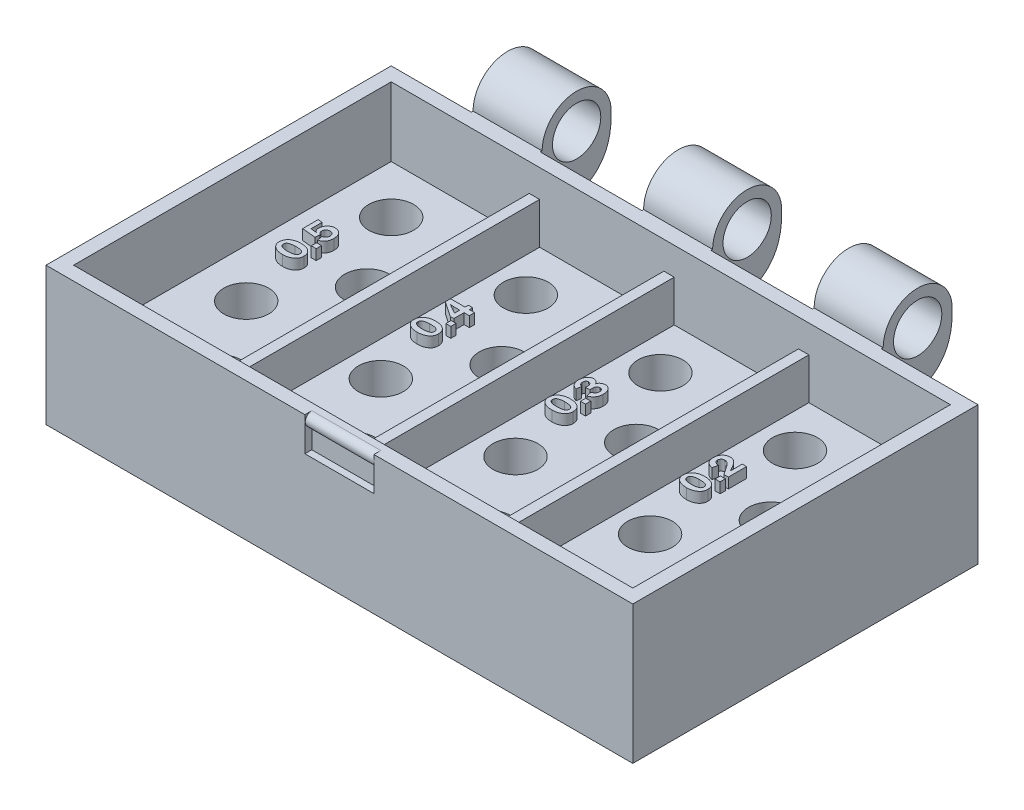
from build123d import *

# Parameters (mm, degrees)
ESQUISSE1_W                  = 85
ESQUISSE1_H                  = 50
BOSS_EXTRU_1_DEPTH           = 20
COQUE1_T                     = -2
COQUE1_THICKNESS_2_FACE_W    = 46
COQUE1_THICKNESS_2_FACE_H    = 81
COQUE1_THICKNESS_2_DEPTH     = 8
ESQUISSE2_R                  = 3.25
ENL_V_MAT_EXTRU_1_DEPTH      = 6
R_P_TITION_LIN_AIRE1_COUNT   = 4
R_P_TITION_LIN_AIRE1_PITCH   = 19.5
ESQUISSE3_W                  = 1.5
ESQUISSE3_H                  = 46
BOSS_EXTRU_2_DEPTH           = 6
R_P_TITION_LIN_AIRE2_COUNT   = 3
R_P_TITION_LIN_AIRE2_PITCH   = 19.5
ESQUISSE6_W                  = 0.719178082
ESQUISSE6_H                  = 0.767123288
BOSS_EXTRU_4_DEPTH           = 1.5
ESQUISSE7_R                  = 5
BOSS_EXTRU_5_DEPTH           = 10
ESQUISSE8_R                  = 3.5
ENL_V_MAT_EXTRU_2_DEPTH      = 10
R_P_TITION_LIN_AIRE4_COUNT   = 3
R_P_TITION_LIN_AIRE4_PITCH   = 24.7
ENL_V_MAT_EXTRU_3_DEPTH      = 5
ENL_V_MAT_EXTRU_3_DEPTH_BACK = 5


with BuildPart() as part:
    # Esquisse1 → Boss.-Extru.1 (new body)
    with BuildSketch(Plane(origin=(0, 0, 0), x_dir=(1, 0, 0), z_dir=(0, 1, 0))):
        Rectangle(ESQUISSE1_W, ESQUISSE1_H)
    extrude(amount=BOSS_EXTRU_1_DEPTH)

    # Coque1
    coque1_openings = [part.faces().sort_by_distance(p)[0] for p in [
        (0, 20, 0),
    ]]
    offset(amount=COQUE1_T, openings=coque1_openings, kind=Kind.INTERSECTION)

    # Coque1 thickness 2 face (on inner face of the shell) → Coque1 thickness 2 (add)
    with BuildSketch(Plane(origin=(0, 2, 0), x_dir=(0, 0, -1), z_dir=(0, -1, 0))):
        Rectangle(COQUE1_THICKNESS_2_FACE_W, COQUE1_THICKNESS_2_FACE_H)
    extrude(amount=-COQUE1_THICKNESS_2_DEPTH)

    # Esquisse2 → Enlèv. mat.-Extru.1 (cut)
    with BuildSketch(Plane(origin=(0, 10, 0), x_dir=(1, 0, 0), z_dir=(0, 1, 0))):
        with Locations(Location((-26.5, 5.5, 0), (0, 0, 270))):
            Circle(ESQUISSE2_R)
        with Locations(Location((-26.5, -16, 0), (0, 0, 270))):
            Circle(ESQUISSE2_R)
        with Locations(Location((-33.5, -5, 0), (0, 0, 270))):
            Circle(ESQUISSE2_R)
        with Locations(Location((-33.5, 16, 0), (0, 0, 270))):
            Circle(ESQUISSE2_R)
    enl_v_mat_extru_1 = extrude(amount=-ENL_V_MAT_EXTRU_1_DEPTH, mode=Mode.SUBTRACT)

    # Répétition linéaire1: Enlèv. mat.-Extru.1 ×4
    with Locations(*[(i * R_P_TITION_LIN_AIRE1_PITCH, 0, 0) for i in range(1, R_P_TITION_LIN_AIRE1_COUNT)]):
        add(enl_v_mat_extru_1, mode=Mode.SUBTRACT)

    # Esquisse3 → Boss.-Extru.2 (add)
    with BuildSketch(Plane(origin=(0, 10, 0), x_dir=(1, 0, 0), z_dir=(0, 1, 0))):
        with Locations((-19.75, 0)):
            Rectangle(ESQUISSE3_W, ESQUISSE3_H)
    boss_extru_2 = extrude(amount=BOSS_EXTRU_2_DEPTH)

    # Répétition linéaire2: Boss.-Extru.2 ×3
    with Locations(*[(i * R_P_TITION_LIN_AIRE2_PITCH, 0, 0) for i in range(1, R_P_TITION_LIN_AIRE2_COUNT)]):
        add(boss_extru_2)

    # Esquisse6 → Boss.-Extru.4 (add)
    with BuildSketch(Plane(origin=(0, 10, 0), x_dir=(1, 0, 0), z_dir=(0, 1, 0))):
        with BuildLine():
            Line((-37, 6.679152397), (-37, 8.928082192))
            Line((-37, 8.928082192), (-36.376712329, 8.867401541))
            Line((-36.376712329, 8.867401541), (-36.376712329, 7.267979452))
            Line((-36.376712329, 7.267979452), (-35.505458048, 7.174336473))
            add(Edge.make_bspline(
                [(-35.505458048, 7.174336473), (-35.536788442, 7.190319678), (-35.597993464, 7.221543429), (-35.677964947, 7.28451081), (-35.747036538, 7.356149542), (-35.801696297, 7.439908994), (-35.844762934, 7.533057182), (-35.875351885, 7.636477261), (-35.894328605, 7.749979407), (-35.89626044, 7.829259295), (-35.897260274, 7.870291096)],
                knots=[0, 0, 0, 0, 0.992987196, 1.939835233, 2.864410788, 3.797156695, 4.754959799, 5.758547693, 6.839922347, 8, 8, 8, 8], degree=3))
            add(Edge.make_bspline(
                [(-35.897260274, 7.870291096), (-35.896442983, 7.914306971), (-35.894838897, 8.000696413), (-35.87657293, 8.127238371), (-35.849403012, 8.248304314), (-35.810314185, 8.363626685), (-35.759486092, 8.472740789), (-35.698950694, 8.577023251), (-35.625584511, 8.674370878), (-35.542881375, 8.765226882), (-35.452799974, 8.847557534), (-35.358768745, 8.920719258), (-35.260520581, 8.981547302), (-35.159760441, 9.032429891), (-35.055005573, 9.071679877), (-34.9466723, 9.098956569), (-34.835101776, 9.117372213), (-34.759385456, 9.119026587), (-34.721104452, 9.119863014)],
                knots=[0, 0, 0, 0, 1.107094003, 2.17288043, 3.211198401, 4.226878603, 5.230841999, 6.236594203, 7.256079046, 8.292778735, 9.324838043, 10.324285764, 11.287009906, 12.228657515, 13.161453271, 14.095941559, 15.037337412, 16, 16, 16, 16], degree=3))
            add(Edge.make_bspline(
                [(-34.721104452, 9.119863014), (-34.681341285, 9.118656571), (-34.60244036, 9.116262662), (-34.486099148, 9.098798041), (-34.373354368, 9.069350181), (-34.264532111, 9.02781339), (-34.158913087, 8.975212582), (-34.057617206, 8.91018366), (-33.959725849, 8.834082224), (-33.866576909, 8.746921976), (-33.780423638, 8.64942117), (-33.70525665, 8.541509548), (-33.640910856, 8.424703728), (-33.589606205, 8.298016432), (-33.548846819, 8.162642969), (-33.520978793, 8.018047737), (-33.503323629, 7.864485401), (-33.501128411, 7.758969042), (-33.5, 7.704730308)],
                knots=[0, 0, 0, 0, 0.912745112, 1.811134253, 2.694171492, 3.583292575, 4.480693289, 5.398394714, 6.342229601, 7.323843977, 8.323245794, 9.323683117, 10.337193912, 11.378459732, 12.455889876, 13.578032625, 14.755032447, 16, 16, 16, 16], degree=3))
            add(Edge.make_bspline(
                [(-33.5, 7.704730308), (-33.500775705, 7.663506791), (-33.502310817, 7.581925849), (-33.512806257, 7.461534651), (-33.530682073, 7.344871315), (-33.556424318, 7.232356809), (-33.588251851, 7.123498417), (-33.628405645, 7.01869055), (-33.675530385, 6.917836095), (-33.729174886, 6.820848616), (-33.7910182, 6.729624251), (-33.86352779, 6.646698683), (-33.945718391, 6.572390008), (-34.037154443, 6.505696778), (-34.138729686, 6.448362019), (-34.249582539, 6.398791865), (-34.369912236, 6.357263902), (-34.454455206, 6.337302819), (-34.497859589, 6.327054795)],
                knots=[0, 0, 0, 0, 1.06162628, 2.100948116, 3.109654542, 4.0987975, 5.071453937, 6.028161296, 6.986251055, 7.936342776, 8.879991641, 9.81893904, 10.765913088, 11.728116642, 12.727616964, 13.763909979, 14.851990799, 16, 16, 16, 16], degree=3))
            Line((-34.497859589, 6.327054795), (-34.602739726, 7.073202055))
            add(Edge.make_bspline(
                [(-34.602739726, 7.073202055), (-34.561123565, 7.088188019), (-34.481426963, 7.116886735), (-34.372971034, 7.174115585), (-34.281365429, 7.241082059), (-34.205543982, 7.316696614), (-34.146710976, 7.401962522), (-34.105135513, 7.496489145), (-34.079667848, 7.600020097), (-34.076812193, 7.672118237), (-34.075342466, 7.709225171)],
                knots=[0, 0, 0, 0, 1.190002395, 2.278901834, 3.288895901, 4.235075517, 5.14897565, 6.061093045, 7.002097791, 8, 8, 8, 8], degree=3))
            add(Edge.make_bspline(
                [(-34.075342466, 7.709225171), (-34.075943352, 7.734468311), (-34.077106855, 7.783346851), (-34.085369095, 7.854590848), (-34.09948881, 7.921353861), (-34.119423854, 7.983838343), (-34.146342116, 8.041230788), (-34.177271495, 8.094889384), (-34.215641674, 8.142983698), (-34.257935919, 8.187327219), (-34.305254456, 8.225737139), (-34.354873364, 8.260051288), (-34.407680192, 8.288176843), (-34.462215944, 8.312642176), (-34.519856358, 8.330632899), (-34.57987339, 8.342932825), (-34.642177138, 8.351917259), (-34.684612922, 8.352463077), (-34.706121575, 8.352739726)],
                knots=[0, 0, 0, 0, 1.193015732, 2.310048108, 3.384166337, 4.41432699, 5.401889314, 6.375529608, 7.334101736, 8.30236177, 9.266512726, 10.209332856, 11.149415557, 12.090164852, 13.030840104, 13.996146252, 14.984343142, 16, 16, 16, 16], degree=3))
            add(Edge.make_bspline(
                [(-34.706121575, 8.352739726), (-34.727379528, 8.35245716), (-34.769315976, 8.351899729), (-34.830650242, 8.343037952), (-34.889615369, 8.330491399), (-34.946107721, 8.312791809), (-34.99936841, 8.288187968), (-35.05072598, 8.259777174), (-35.099553312, 8.226057266), (-35.144810445, 8.187006186), (-35.18705162, 8.144879068), (-35.222830608, 8.098274643), (-35.253215739, 8.048699637), (-35.278849878, 7.996461801), (-35.298408636, 7.940627445), (-35.311724309, 7.881535244), (-35.320086542, 7.819587201), (-35.321301739, 7.777174202), (-35.321917808, 7.755672089)],
                knots=[0, 0, 0, 0, 1.061408398, 2.093884465, 3.090127335, 4.072834524, 5.044705628, 6.016817066, 7.003399267, 8.003698264, 9.000878628, 9.979377201, 10.931825108, 11.902974853, 12.881791689, 13.880766456, 14.925612437, 16, 16, 16, 16], degree=3))
            add(Edge.make_bspline(
                [(-35.321917808, 7.755672089), (-35.320810887, 7.725861776), (-35.318631829, 7.667177945), (-35.299997688, 7.58157188), (-35.269698215, 7.500342565), (-35.227106063, 7.423276523), (-35.172714585, 7.350186296), (-35.105989527, 7.281792642), (-35.027414468, 7.217668397), (-34.968737809, 7.180234457), (-34.938356164, 7.160851884)],
                knots=[0, 0, 0, 0, 0.962510054, 1.894773007, 2.816638911, 3.755688375, 4.730568976, 5.752162559, 6.836113034, 8, 8, 8, 8], degree=3))
            Line((-34.938356164, 7.160851884), (-35.041738014, 6.482876712))
            Line((-35.041738014, 6.482876712), (-37, 6.679152397))
        make_face()
        with Locations((-33.859589041, 5.523972603)):
            Rectangle(ESQUISSE6_W, ESQUISSE6_H)
        with BuildLine():
            add(Edge.make_bspline(
                [(-33.452054795, 3.308754281), (-33.453277057, 3.256709262), (-33.45566497, 3.155029823), (-33.480594161, 3.007557096), (-33.519189341, 2.869026264), (-33.574313111, 2.739791372), (-33.64520614, 2.620015611), (-33.731590094, 2.509260557), (-33.834206122, 2.408761505), (-33.951513136, 2.318544256), (-34.08013711, 2.238363245), (-34.217700769, 2.167290326), (-34.36422218, 2.108682552), (-34.51832965, 2.059524118), (-34.680793765, 2.022419993), (-34.85124655, 1.995714689), (-35.029904844, 1.978674456), (-35.151822794, 1.976921819), (-35.214041096, 1.976027397)],
                knots=[0, 0, 0, 0, 1.005007233, 1.963464982, 2.881621689, 3.778955867, 4.670391392, 5.564370843, 6.485806895, 7.4386222, 8.418802495, 9.411696762, 10.427102608, 11.465014262, 12.53503646, 13.644273268, 14.797803629, 16, 16, 16, 16], degree=3))
            add(Edge.make_bspline(
                [(-35.214041096, 1.976027397), (-35.280995538, 1.977269139), (-35.411864816, 1.979696249), (-35.603140375, 1.995951582), (-35.784381005, 2.02435189), (-35.955554331, 2.064181654), (-36.117520898, 2.113860798), (-36.269308898, 2.176378945), (-36.411445715, 2.249686971), (-36.542479415, 2.334154287), (-36.660695195, 2.428013347), (-36.7644758, 2.530352621), (-36.852211705, 2.641223996), (-36.923823732, 2.760369049), (-36.979840793, 2.887445888), (-37.019604463, 3.02234395), (-37.043095824, 3.165348052), (-37.046304785, 3.263218028), (-37.047945205, 3.313249144)],
                knots=[0, 0, 0, 0, 1.263317377, 2.469282517, 3.618848679, 4.721775781, 5.782855962, 6.811846994, 7.814967656, 8.796487561, 9.748685278, 10.658252565, 11.540562543, 12.409229823, 13.274196187, 14.153797078, 15.05622136, 16, 16, 16, 16], degree=3))
            add(Edge.make_bspline(
                [(-37.047945205, 3.313249144), (-37.047330518, 3.351740432), (-37.046125929, 3.427170937), (-37.033578612, 3.53781999), (-37.01432416, 3.643784024), (-36.987373468, 3.745026418), (-36.95312288, 3.841539305), (-36.909861959, 3.932515699), (-36.859717961, 4.019321297), (-36.801016775, 4.100470741), (-36.73657551, 4.177279934), (-36.665901483, 4.248085391), (-36.590797048, 4.314779463), (-36.509686499, 4.374973794), (-36.42425344, 4.430988897), (-36.332702113, 4.480278104), (-36.236608814, 4.525375539), (-36.10271786, 4.576001235), (-35.935449234, 4.627869147), (-35.738213682, 4.673820438), (-35.548316208, 4.703587071), (-35.423902733, 4.707159033), (-35.363120719, 4.70890411)],
                knots=[0, 0, 0, 0, 0.94187537, 1.845771813, 2.72221507, 3.57628802, 4.407725887, 5.22534137, 6.038925102, 6.858252631, 7.673808914, 8.490761443, 9.305033817, 10.130268942, 10.961077375, 11.803609458, 12.673290332, 13.557628104, 15.305455095, 16.95581214, 18.512766662, 20, 20, 20, 20], degree=3))
            add(Edge.make_bspline(
                [(-35.363120719, 4.70890411), (-35.314423312, 4.708392049), (-35.218989156, 4.707388544), (-35.079002427, 4.701907709), (-34.945400976, 4.690151928), (-34.818100669, 4.675762024), (-34.697483069, 4.655936827), (-34.583208303, 4.633433524), (-34.475928115, 4.604427248), (-34.374264246, 4.572405785), (-34.27750571, 4.535578353), (-34.185257655, 4.493005752), (-34.097437099, 4.443920993), (-34.013344904, 4.389914406), (-33.932798135, 4.330618108), (-33.856509703, 4.265459092), (-33.784214976, 4.19458846), (-33.716248507, 4.118579389), (-33.653508039, 4.037144552), (-33.599630312, 3.949104462), (-33.553819951, 3.855796062), (-33.515852481, 3.757151662), (-33.488077157, 3.652514238), (-33.466620819, 3.542975416), (-33.454922697, 3.427621078), (-33.453025376, 3.348982247), (-33.452054795, 3.308754281)],
                knots=[0, 0, 0, 0, 1.308115475, 2.563563526, 3.761728665, 4.90986614, 6.003763084, 7.044289273, 8.036748608, 8.987084304, 9.906402131, 10.81570635, 11.713458321, 12.606537478, 13.498658964, 14.397888098, 15.299091339, 16.215958955, 17.134909667, 18.056378292, 18.983299153, 19.923807997, 20.890361836, 21.887502022, 22.919344344, 24, 24, 24, 24], degree=3))
        make_face()
        with BuildLine():
            add(Edge.make_bspline(
                [(-34.02739726, 3.3125), (-34.029010421, 3.349625522), (-34.032130991, 3.421442768), (-34.059407377, 3.52371806), (-34.106085564, 3.61435351), (-34.171611183, 3.692759616), (-34.253538604, 3.759876227), (-34.352333048, 3.814540382), (-34.466166276, 3.858770753), (-34.572532587, 3.884214759), (-34.666223411, 3.90050561), (-34.745119076, 3.912038432), (-34.830938505, 3.920244724), (-34.92375181, 3.929107055), (-35.023453631, 3.934842652), (-35.130375672, 3.93809328), (-35.243984805, 3.941662627), (-35.32216425, 3.94174068), (-35.362371575, 3.941780822)],
                knots=[0, 0, 0, 0, 1.073429503, 2.076489368, 3.036773514, 4.002186882, 5.013884472, 6.085413537, 7.257387958, 8.539074557, 9.243873084, 10.010643218, 10.846512546, 11.739250192, 12.709684899, 13.736864371, 14.836079867, 16, 16, 16, 16], degree=3))
            add(Edge.make_bspline(
                [(-35.362371575, 3.941780822), (-35.428377608, 3.940242865), (-35.559110903, 3.937196747), (-35.751825589, 3.911546211), (-35.939040446, 3.871328424), (-36.088653369, 3.823939129), (-36.201119968, 3.777985747), (-36.273102289, 3.733334065), (-36.335765644, 3.683732243), (-36.385572045, 3.624678562), (-36.42564669, 3.55984727), (-36.451926447, 3.487057223), (-36.470412049, 3.408314256), (-36.471855718, 3.353071477), (-36.47260274, 3.324486301)],
                knots=[0, 0, 0, 0, 1.67541373, 3.318368768, 4.927723713, 6.531949127, 7.298762037, 8.004526205, 8.675958752, 9.319007099, 9.956245832, 10.60041861, 11.275791663, 12, 12, 12, 12], degree=3))
            add(Edge.make_bspline(
                [(-36.47260274, 3.324486301), (-36.471846413, 3.300934116), (-36.470367193, 3.254870818), (-36.455598577, 3.188137691), (-36.431771013, 3.125946128), (-36.396970373, 3.069096713), (-36.354006064, 3.016039183), (-36.301070076, 2.968056256), (-36.238351708, 2.925047275), (-36.166585412, 2.886247267), (-36.084684857, 2.852932615), (-35.994226816, 2.822831056), (-35.893922864, 2.798445487), (-35.784288961, 2.778646945), (-35.665142737, 2.76184017), (-35.536330576, 2.751238124), (-35.398158007, 2.744299459), (-35.302948916, 2.743542088), (-35.253745719, 2.743150685)],
                knots=[0, 0, 0, 0, 0.754198635, 1.475059561, 2.179865867, 2.880200645, 3.603015608, 4.362466504, 5.162094305, 6.036298937, 6.97312904, 7.993554671, 9.090789647, 10.279647763, 11.564904973, 12.947352574, 14.422419413, 16, 16, 16, 16], degree=3))
            add(Edge.make_bspline(
                [(-35.253745719, 2.743150685), (-35.207042861, 2.743623633), (-35.116344646, 2.74454211), (-34.984149209, 2.750440177), (-34.859903873, 2.760648989), (-34.743491144, 2.775838626), (-34.634610699, 2.794117522), (-34.533626496, 2.81738276), (-34.440143924, 2.844119336), (-34.354855482, 2.875309781), (-34.278068885, 2.910683248), (-34.211065958, 2.952088357), (-34.154583233, 2.999329187), (-34.107941246, 3.051742434), (-34.07130604, 3.109256428), (-34.045622708, 3.172429703), (-34.030382883, 3.24086055), (-34.028410021, 3.288198992), (-34.02739726, 3.3125)],
                knots=[0, 0, 0, 0, 1.497746712, 2.908664615, 4.242763532, 5.494342263, 6.672680141, 7.781939517, 8.815973326, 9.788908864, 10.691683796, 11.522736518, 12.307142226, 13.044689772, 13.764547329, 14.482844097, 15.221173818, 16, 16, 16, 16], degree=3))
        make_face(mode=Mode.SUBTRACT)
        Polygon((-14, 8.592465753), (-14, 7.825342466), (-14.767123288, 7.825342466), (-14.767123288, 6.339041096), (-15.282534247, 6.339041096), (-17.5, 7.847816781), (-17.5, 8.592465753), (-15.390410959, 8.592465753), (-15.390410959, 9.071917808), (-14.767123288, 9.071917808), (-14.767123288, 8.592465753), align=None)
        with BuildLine():
            Line((-16.805543664, 7.870291096), (-15.390410959, 7.067958048))
            Line((-15.390410959, 7.067958048), (-15.390410959, 7.825342466))
            Line((-15.390410959, 7.825342466), (-16.266909247, 7.825342466))
            add(Edge.make_bspline(
                [(-16.266909247, 7.825342466), (-16.314900716, 7.82578794), (-16.40503748, 7.826624623), (-16.494684651, 7.835960269), (-16.536601027, 7.840325342)],
                knots=[0, 0, 0, 0, 1.064858921, 2, 2, 2, 2], degree=3))
            Line((-16.536601027, 7.840325342), (-16.805543664, 7.870291096))
        make_face(mode=Mode.SUBTRACT)
        with Locations((-14.359589041, 5.523972603)):
            Rectangle(ESQUISSE6_W, ESQUISSE6_H)
        with BuildLine():
            add(Edge.make_bspline(
                [(-13.952054795, 3.308754281), (-13.953277057, 3.256709262), (-13.95566497, 3.155029823), (-13.980594161, 3.007557096), (-14.019189341, 2.869026264), (-14.074313111, 2.739791372), (-14.14520614, 2.620015611), (-14.231590094, 2.509260557), (-14.334206122, 2.408761505), (-14.451513136, 2.318544256), (-14.58013711, 2.238363245), (-14.717700769, 2.167290326), (-14.86422218, 2.108682552), (-15.01832965, 2.059524118), (-15.180793765, 2.022419993), (-15.35124655, 1.995714689), (-15.529904844, 1.978674456), (-15.651822794, 1.976921819), (-15.714041096, 1.976027397)],
                knots=[0, 0, 0, 0, 1.005007233, 1.963464982, 2.881621689, 3.778955867, 4.670391392, 5.564370843, 6.485806895, 7.4386222, 8.418802495, 9.411696762, 10.427102608, 11.465014262, 12.53503646, 13.644273268, 14.797803629, 16, 16, 16, 16], degree=3))
            add(Edge.make_bspline(
                [(-15.714041096, 1.976027397), (-15.780995538, 1.977269139), (-15.911864816, 1.979696249), (-16.103140375, 1.995951582), (-16.284381005, 2.02435189), (-16.455554331, 2.064181654), (-16.617520898, 2.113860798), (-16.769308898, 2.176378945), (-16.911445715, 2.249686971), (-17.042479415, 2.334154287), (-17.160695195, 2.428013347), (-17.2644758, 2.530352621), (-17.352211705, 2.641223996), (-17.423823732, 2.760369049), (-17.479840793, 2.887445888), (-17.519604463, 3.02234395), (-17.543095824, 3.165348052), (-17.546304785, 3.263218028), (-17.547945205, 3.313249144)],
                knots=[0, 0, 0, 0, 1.263317377, 2.469282517, 3.618848679, 4.721775781, 5.782855962, 6.811846994, 7.814967656, 8.796487561, 9.748685278, 10.658252565, 11.540562543, 12.409229823, 13.274196187, 14.153797078, 15.05622136, 16, 16, 16, 16], degree=3))
            add(Edge.make_bspline(
                [(-17.547945205, 3.313249144), (-17.547330518, 3.351740432), (-17.546125929, 3.427170937), (-17.533578612, 3.53781999), (-17.51432416, 3.643784024), (-17.487373468, 3.745026418), (-17.45312288, 3.841539305), (-17.409861959, 3.932515699), (-17.359717961, 4.019321297), (-17.301016775, 4.100470741), (-17.23657551, 4.177279934), (-17.165901483, 4.248085391), (-17.090797048, 4.314779463), (-17.009686499, 4.374973794), (-16.92425344, 4.430988897), (-16.832702113, 4.480278104), (-16.736608814, 4.525375539), (-16.60271786, 4.576001235), (-16.435449234, 4.627869147), (-16.238213682, 4.673820438), (-16.048316208, 4.703587071), (-15.923902733, 4.707159033), (-15.863120719, 4.70890411)],
                knots=[0, 0, 0, 0, 0.94187537, 1.845771813, 2.72221507, 3.57628802, 4.407725887, 5.22534137, 6.038925102, 6.858252631, 7.673808914, 8.490761443, 9.305033817, 10.130268942, 10.961077375, 11.803609458, 12.673290332, 13.557628104, 15.305455095, 16.95581214, 18.512766662, 20, 20, 20, 20], degree=3))
            add(Edge.make_bspline(
                [(-15.863120719, 4.70890411), (-15.814423312, 4.708392049), (-15.718989156, 4.707388544), (-15.579002427, 4.701907709), (-15.445400976, 4.690151928), (-15.318100669, 4.675762024), (-15.197483069, 4.655936827), (-15.083208303, 4.633433524), (-14.975928115, 4.604427248), (-14.874264246, 4.572405785), (-14.77750571, 4.535578353), (-14.685257655, 4.493005752), (-14.597437099, 4.443920993), (-14.513344904, 4.389914406), (-14.432798135, 4.330618108), (-14.356509703, 4.265459092), (-14.284214976, 4.19458846), (-14.216248507, 4.118579389), (-14.153508039, 4.037144552), (-14.099630312, 3.949104462), (-14.053819951, 3.855796062), (-14.015852481, 3.757151662), (-13.988077157, 3.652514238), (-13.966620819, 3.542975416), (-13.954922697, 3.427621078), (-13.953025376, 3.348982247), (-13.952054795, 3.308754281)],
                knots=[0, 0, 0, 0, 1.308115475, 2.563563526, 3.761728665, 4.90986614, 6.003763084, 7.044289273, 8.036748608, 8.987084304, 9.906402131, 10.81570635, 11.713458321, 12.606537478, 13.498658964, 14.397888098, 15.299091339, 16.215958955, 17.134909667, 18.056378292, 18.983299153, 19.923807997, 20.890361836, 21.887502022, 22.919344344, 24, 24, 24, 24], degree=3))
        make_face()
        with BuildLine():
            add(Edge.make_bspline(
                [(-14.52739726, 3.3125), (-14.529010421, 3.349625522), (-14.532130991, 3.421442768), (-14.559407377, 3.52371806), (-14.606085564, 3.61435351), (-14.671611183, 3.692759616), (-14.753538604, 3.759876227), (-14.852333048, 3.814540382), (-14.966166276, 3.858770753), (-15.072532587, 3.884214759), (-15.166223411, 3.90050561), (-15.245119076, 3.912038432), (-15.330938505, 3.920244724), (-15.42375181, 3.929107055), (-15.523453631, 3.934842652), (-15.630375672, 3.93809328), (-15.743984805, 3.941662627), (-15.82216425, 3.94174068), (-15.862371575, 3.941780822)],
                knots=[0, 0, 0, 0, 1.073429503, 2.076489368, 3.036773514, 4.002186882, 5.013884472, 6.085413537, 7.257387958, 8.539074557, 9.243873084, 10.010643218, 10.846512546, 11.739250192, 12.709684899, 13.736864371, 14.836079867, 16, 16, 16, 16], degree=3))
            add(Edge.make_bspline(
                [(-15.862371575, 3.941780822), (-15.928377608, 3.940242865), (-16.059110903, 3.937196747), (-16.251825589, 3.911546211), (-16.439040446, 3.871328424), (-16.588653369, 3.823939129), (-16.701119968, 3.777985747), (-16.773102289, 3.733334065), (-16.835765644, 3.683732243), (-16.885572045, 3.624678562), (-16.92564669, 3.55984727), (-16.951926447, 3.487057223), (-16.970412049, 3.408314256), (-16.971855718, 3.353071477), (-16.97260274, 3.324486301)],
                knots=[0, 0, 0, 0, 1.67541373, 3.318368768, 4.927723713, 6.531949127, 7.298762037, 8.004526205, 8.675958752, 9.319007099, 9.956245832, 10.60041861, 11.275791663, 12, 12, 12, 12], degree=3))
            add(Edge.make_bspline(
                [(-16.97260274, 3.324486301), (-16.971846413, 3.300934116), (-16.970367193, 3.254870818), (-16.955598577, 3.188137691), (-16.931771013, 3.125946128), (-16.896970373, 3.069096713), (-16.854006064, 3.016039183), (-16.801070076, 2.968056256), (-16.738351708, 2.925047275), (-16.666585412, 2.886247267), (-16.584684857, 2.852932615), (-16.494226816, 2.822831056), (-16.393922864, 2.798445487), (-16.284288961, 2.778646945), (-16.165142737, 2.76184017), (-16.036330576, 2.751238124), (-15.898158007, 2.744299459), (-15.802948916, 2.743542088), (-15.753745719, 2.743150685)],
                knots=[0, 0, 0, 0, 0.754198635, 1.475059561, 2.179865867, 2.880200645, 3.603015608, 4.362466504, 5.162094305, 6.036298937, 6.97312904, 7.993554671, 9.090789647, 10.279647763, 11.564904973, 12.947352574, 14.422419413, 16, 16, 16, 16], degree=3))
            add(Edge.make_bspline(
                [(-15.753745719, 2.743150685), (-15.707042861, 2.743623633), (-15.616344646, 2.74454211), (-15.484149209, 2.750440177), (-15.359903873, 2.760648989), (-15.243491144, 2.775838626), (-15.134610699, 2.794117522), (-15.033626496, 2.81738276), (-14.940143924, 2.844119336), (-14.854855482, 2.875309781), (-14.778068885, 2.910683248), (-14.711065958, 2.952088357), (-14.654583233, 2.999329187), (-14.607941246, 3.051742434), (-14.57130604, 3.109256428), (-14.545622708, 3.172429703), (-14.530382883, 3.24086055), (-14.528410021, 3.288198992), (-14.52739726, 3.3125)],
                knots=[0, 0, 0, 0, 1.497746712, 2.908664615, 4.242763532, 5.494342263, 6.672680141, 7.781939517, 8.815973326, 9.788908864, 10.691683796, 11.522736518, 12.307142226, 13.044689772, 13.764547329, 14.482844097, 15.221173818, 16, 16, 16, 16], degree=3))
        make_face(mode=Mode.SUBTRACT)
        with BuildLine():
            Line((4.01369863, 7.25), (3.390410959, 7.25))
            Line((3.390410959, 7.25), (3.390410959, 7.592358733))
            add(Edge.make_bspline(
                [(3.390410959, 7.592358733), (3.389328854, 7.632170145), (3.387256638, 7.708408398), (3.365676123, 7.817181361), (3.33142233, 7.914878073), (3.291347832, 7.987887897), (3.251945066, 8.038190996), (3.220089768, 8.07191437), (3.183056203, 8.098506837), (3.14440237, 8.122670106), (3.100992621, 8.139298503), (3.055184124, 8.152322758), (3.005852765, 8.159934312), (2.971915172, 8.160610241), (2.954409247, 8.160958904)],
                knots=[0, 0, 0, 0, 1.771537598, 3.392467764, 4.915960241, 6.3702638, 7.075647893, 7.760018843, 8.427455223, 9.100890115, 9.784627933, 10.489046527, 11.220609441, 12, 12, 12, 12], degree=3))
            add(Edge.make_bspline(
                [(2.954409247, 8.160958904), (2.920982148, 8.159713207), (2.85720604, 8.15733652), (2.768427333, 8.13020898), (2.691755938, 8.087072509), (2.631736732, 8.024099102), (2.583912958, 7.949287074), (2.551570321, 7.862102216), (2.530736251, 7.765143911), (2.528540986, 7.696857128), (2.52739726, 7.661279966)],
                knots=[0, 0, 0, 0, 1.073558352, 2.048259583, 2.960261916, 3.876087877, 4.820063252, 5.803061369, 6.855403046, 8, 8, 8, 8], degree=3))
            add(Edge.make_bspline(
                [(2.52739726, 7.661279966), (2.528744827, 7.628180899), (2.53137131, 7.56366896), (2.554575521, 7.470788472), (2.592583863, 7.385311922), (2.646105474, 7.307173302), (2.714445399, 7.236086633), (2.798346058, 7.173193056), (2.896303468, 7.116428641), (2.968966047, 7.08703066), (3.006849315, 7.071703767)],
                knots=[0, 0, 0, 0, 0.973990299, 1.898361795, 2.800804568, 3.717088155, 4.674598404, 5.692932824, 6.797190455, 8, 8, 8, 8], degree=3))
            Line((3.006849315, 7.071703767), (2.901969178, 6.375))
            add(Edge.make_bspline(
                [(2.901969178, 6.375), (2.865572746, 6.383831193), (2.793847637, 6.401234499), (2.690819701, 6.438377322), (2.593953853, 6.483521052), (2.502716305, 6.535750409), (2.418289284, 6.597266778), (2.339589514, 6.666005843), (2.267125227, 6.743076664), (2.20171061, 6.827691092), (2.142295576, 6.918091033), (2.091585703, 7.014085036), (2.048655949, 7.11436348), (2.013470548, 7.218843635), (1.985587209, 7.327473487), (1.966411744, 7.440742484), (1.953933657, 7.55811636), (1.952686623, 7.638023928), (1.952054795, 7.678510274)],
                knots=[0, 0, 0, 0, 1.024397509, 2.018742455, 2.991025302, 3.946347863, 4.890952695, 5.845003318, 6.802255011, 7.78104886, 8.768607033, 9.759140141, 10.748021611, 11.750785432, 12.773471828, 13.813861142, 14.892360559, 16, 16, 16, 16], degree=3))
            add(Edge.make_bspline(
                [(1.952054795, 7.678510274), (1.953035328, 7.72098518), (1.954965686, 7.804604803), (1.966702138, 7.927643397), (1.987897468, 8.045792319), (2.017073215, 8.159281659), (2.054464611, 8.26808672), (2.100239768, 8.371894419), (2.154609107, 8.470506522), (2.216107075, 8.563513325), (2.284369719, 8.648763632), (2.358841187, 8.723223753), (2.437597677, 8.786937736), (2.521948368, 8.838251849), (2.6106814, 8.879376056), (2.705004175, 8.907747826), (2.804237224, 8.924438337), (2.871939097, 8.926851557), (2.906464041, 8.928082192)],
                knots=[0, 0, 0, 0, 1.164746089, 2.29301579, 3.384986046, 4.452839496, 5.503051141, 6.536159416, 7.559693225, 8.587090345, 9.590150253, 10.548804952, 11.469515749, 12.360834001, 13.249386426, 14.143959975, 15.053502155, 16, 16, 16, 16], degree=3))
            add(Edge.make_bspline(
                [(2.906464041, 8.928082192), (2.931969033, 8.927588403), (2.982422206, 8.926611607), (3.056833673, 8.916344682), (3.129012974, 8.900693845), (3.199110137, 8.879010556), (3.266852339, 8.850382511), (3.332071738, 8.814879701), (3.39523864, 8.773563587), (3.455103702, 8.726675232), (3.510766696, 8.676887735), (3.558830074, 8.624145074), (3.599589566, 8.570839962), (3.633253246, 8.516724356), (3.658157207, 8.460669085), (3.675334128, 8.40354376), (3.685868941, 8.345391716), (3.68567204, 8.306335276), (3.68557363, 8.286815068)],
                knots=[0, 0, 0, 0, 1.101003957, 2.177971462, 3.237898903, 4.288621631, 5.34232953, 6.408876625, 7.49182269, 8.598622832, 9.690555268, 10.713564949, 11.675685961, 12.585798331, 13.459719754, 14.316160983, 15.158425937, 16, 16, 16, 16], degree=3))
            add(Edge.make_bspline(
                [(3.68557363, 8.286815068), (3.685703301, 8.311330354), (3.685959971, 8.359855878), (3.697190946, 8.431397352), (3.714697368, 8.500738775), (3.741627821, 8.567064212), (3.775155446, 8.631239188), (3.817860468, 8.692031014), (3.86757679, 8.75087401), (3.92455993, 8.806301433), (3.987233893, 8.856485789), (4.052080712, 8.901934454), (4.120038532, 8.939429937), (4.189955693, 8.970367332), (4.262429264, 8.994510071), (4.337147379, 9.011787903), (4.414485486, 9.021514754), (4.466654903, 9.023144757), (4.493150685, 9.023972603)],
                knots=[0, 0, 0, 0, 0.968791804, 1.917625274, 2.857100214, 3.792878572, 4.743202909, 5.716218238, 6.725822637, 7.787926936, 8.855806821, 9.900065589, 10.917377004, 11.921648521, 12.921535616, 13.935434273, 14.951449229, 16, 16, 16, 16], degree=3))
            add(Edge.make_bspline(
                [(4.493150685, 9.023972603), (4.529669649, 9.022766961), (4.601869539, 9.020383346), (4.707871067, 9.003076982), (4.809181933, 8.973205335), (4.90662611, 8.933240021), (4.998078775, 8.878919367), (5.085932397, 8.814772972), (5.1692678, 8.738857444), (5.246617235, 8.651138042), (5.31767588, 8.554433232), (5.379316298, 8.448579337), (5.432005964, 8.335066544), (5.474548207, 8.213305567), (5.507357783, 8.083634692), (5.531196185, 7.946427133), (5.545696755, 7.801183799), (5.547183081, 7.701768076), (5.547945205, 7.650791952)],
                knots=[0, 0, 0, 0, 0.905789234, 1.790792363, 2.655330859, 3.521643042, 4.396067848, 5.286927052, 6.216592694, 7.186322306, 8.183752903, 9.188829696, 10.219859044, 11.283714878, 12.383521698, 13.534360933, 14.735725921, 16, 16, 16, 16], degree=3))
            add(Edge.make_bspline(
                [(5.547945205, 7.650791952), (5.547132196, 7.605557244), (5.545542811, 7.517126051), (5.531621781, 7.387420168), (5.509548714, 7.263861385), (5.477907442, 7.146070265), (5.437277609, 7.034434608), (5.389017029, 6.928051036), (5.329742777, 6.828649269), (5.262688034, 6.735713486), (5.189362048, 6.649679825), (5.111278154, 6.571435514), (5.028954566, 6.501579679), (4.941979694, 6.440531048), (4.851354049, 6.387268226), (4.756570977, 6.341857868), (4.657047647, 6.305757821), (4.588452842, 6.288048118), (4.553831336, 6.279109589)],
                knots=[0, 0, 0, 0, 1.182344505, 2.311413972, 3.406310915, 4.461055321, 5.495746771, 6.509400339, 7.510402046, 8.516013214, 9.502452639, 10.462682737, 11.403110762, 12.321456003, 13.237384541, 14.148507227, 15.065505478, 16, 16, 16, 16], degree=3))
            Line((4.553831336, 6.279109589), (4.397260274, 7.026005993))
            add(Edge.make_bspline(
                [(4.397260274, 7.026005993), (4.442613291, 7.040941379), (4.529162146, 7.069443134), (4.647032827, 7.126753835), (4.747693754, 7.192584776), (4.830233667, 7.269036257), (4.894375307, 7.355690152), (4.940090926, 7.452037262), (4.967829009, 7.557862305), (4.97098338, 7.631643506), (4.97260274, 7.669520548)],
                knots=[0, 0, 0, 0, 1.225294384, 2.338275024, 3.355793167, 4.304195361, 5.212427063, 6.107519097, 7.028457418, 8, 8, 8, 8], degree=3))
            add(Edge.make_bspline(
                [(4.97260274, 7.669520548), (4.971327893, 7.712134039), (4.968885796, 7.793764456), (4.941970695, 7.909016432), (4.899305541, 8.0115694), (4.838399145, 8.09784324), (4.766656985, 8.168062196), (4.686680071, 8.219805636), (4.598836787, 8.251674329), (4.537608781, 8.255110868), (4.506635274, 8.256849315)],
                knots=[0, 0, 0, 0, 1.222031338, 2.34092364, 3.378915038, 4.393820644, 5.352619853, 6.246106466, 7.112755154, 8, 8, 8, 8], degree=3))
            add(Edge.make_bspline(
                [(4.506635274, 8.256849315), (4.474718147, 8.255470135), (4.411743987, 8.25274894), (4.321081099, 8.224780532), (4.236235821, 8.181517061), (4.172353691, 8.131235829), (4.12666127, 8.082631833), (4.095451785, 8.041373632), (4.07026405, 7.994731518), (4.049950092, 7.943557298), (4.033648207, 7.888402262), (4.021416759, 7.828550852), (4.014957963, 7.764057194), (4.014127064, 7.719476642), (4.01369863, 7.696489726)],
                knots=[0, 0, 0, 0, 1.362877594, 2.689028765, 4.023086039, 5.42401243, 6.142559486, 6.875985197, 7.631973666, 8.404266858, 9.229645637, 10.091406174, 11.015878381, 12, 12, 12, 12], degree=3))
            Line((4.01369863, 7.696489726), (4.01369863, 7.25))
        make_face()
        with Locations((5.140410959, 5.523972603)):
            Rectangle(ESQUISSE6_W, ESQUISSE6_H)
        with BuildLine():
            add(Edge.make_bspline(
                [(5.547945205, 3.308754281), (5.546722943, 3.256709262), (5.54433503, 3.155029823), (5.519405839, 3.007557096), (5.480810659, 2.869026264), (5.425686889, 2.739791372), (5.35479386, 2.620015611), (5.268409906, 2.509260557), (5.165793878, 2.408761505), (5.048486864, 2.318544256), (4.91986289, 2.238363245), (4.782299231, 2.167290326), (4.63577782, 2.108682552), (4.48167035, 2.059524118), (4.319206235, 2.022419993), (4.14875345, 1.995714689), (3.970095156, 1.978674456), (3.848177206, 1.976921819), (3.785958904, 1.976027397)],
                knots=[0, 0, 0, 0, 1.005007233, 1.963464982, 2.881621689, 3.778955867, 4.670391392, 5.564370843, 6.485806895, 7.4386222, 8.418802495, 9.411696762, 10.427102608, 11.465014262, 12.53503646, 13.644273268, 14.797803629, 16, 16, 16, 16], degree=3))
            add(Edge.make_bspline(
                [(3.785958904, 1.976027397), (3.719004462, 1.977269139), (3.588135184, 1.979696249), (3.396859625, 1.995951582), (3.215618995, 2.02435189), (3.044445669, 2.064181654), (2.882479102, 2.113860798), (2.730691102, 2.176378945), (2.588554285, 2.249686971), (2.457520585, 2.334154287), (2.339304805, 2.428013347), (2.2355242, 2.530352621), (2.147788295, 2.641223996), (2.076176268, 2.760369049), (2.020159207, 2.887445888), (1.980395537, 3.02234395), (1.956904176, 3.165348052), (1.953695215, 3.263218028), (1.952054795, 3.313249144)],
                knots=[0, 0, 0, 0, 1.263317377, 2.469282517, 3.618848679, 4.721775781, 5.782855962, 6.811846994, 7.814967656, 8.796487561, 9.748685278, 10.658252565, 11.540562543, 12.409229823, 13.274196187, 14.153797078, 15.05622136, 16, 16, 16, 16], degree=3))
            add(Edge.make_bspline(
                [(1.952054795, 3.313249144), (1.952669482, 3.351740432), (1.953874071, 3.427170937), (1.966421388, 3.53781999), (1.98567584, 3.643784024), (2.012626532, 3.745026418), (2.04687712, 3.841539305), (2.090138041, 3.932515699), (2.140282039, 4.019321297), (2.198983225, 4.100470741), (2.26342449, 4.177279934), (2.334098517, 4.248085391), (2.409202952, 4.314779463), (2.490313501, 4.374973794), (2.57574656, 4.430988897), (2.667297887, 4.480278104), (2.763391186, 4.525375539), (2.89728214, 4.576001235), (3.064550766, 4.627869147), (3.261786318, 4.673820438), (3.451683792, 4.703587071), (3.576097267, 4.707159033), (3.636879281, 4.70890411)],
                knots=[0, 0, 0, 0, 0.94187537, 1.845771813, 2.72221507, 3.57628802, 4.407725887, 5.22534137, 6.038925102, 6.858252631, 7.673808914, 8.490761443, 9.305033817, 10.130268942, 10.961077375, 11.803609458, 12.673290332, 13.557628104, 15.305455095, 16.95581214, 18.512766662, 20, 20, 20, 20], degree=3))
            add(Edge.make_bspline(
                [(3.636879281, 4.70890411), (3.685576688, 4.708392049), (3.781010844, 4.707388544), (3.920997573, 4.701907709), (4.054599024, 4.690151928), (4.181899331, 4.675762024), (4.302516931, 4.655936827), (4.416791697, 4.633433524), (4.524071885, 4.604427248), (4.625735754, 4.572405785), (4.72249429, 4.535578353), (4.814742345, 4.493005752), (4.902562901, 4.443920993), (4.986655096, 4.389914406), (5.067201865, 4.330618108), (5.143490297, 4.265459092), (5.215785024, 4.19458846), (5.283751493, 4.118579389), (5.346491961, 4.037144552), (5.400369688, 3.949104462), (5.446180049, 3.855796062), (5.484147519, 3.757151662), (5.511922843, 3.652514238), (5.533379181, 3.542975416), (5.545077303, 3.427621078), (5.546974624, 3.348982247), (5.547945205, 3.308754281)],
                knots=[0, 0, 0, 0, 1.308115475, 2.563563526, 3.761728665, 4.90986614, 6.003763084, 7.044289273, 8.036748608, 8.987084304, 9.906402131, 10.81570635, 11.713458321, 12.606537478, 13.498658964, 14.397888098, 15.299091339, 16.215958955, 17.134909667, 18.056378292, 18.983299153, 19.923807997, 20.890361836, 21.887502022, 22.919344344, 24, 24, 24, 24], degree=3))
        make_face()
        with BuildLine():
            add(Edge.make_bspline(
                [(4.97260274, 3.3125), (4.970989579, 3.349625522), (4.967869009, 3.421442768), (4.940592623, 3.52371806), (4.893914436, 3.61435351), (4.828388817, 3.692759616), (4.746461396, 3.759876227), (4.647666952, 3.814540382), (4.533833724, 3.858770753), (4.427467413, 3.884214759), (4.333776589, 3.90050561), (4.254880924, 3.912038432), (4.169061495, 3.920244724), (4.07624819, 3.929107055), (3.976546369, 3.934842652), (3.869624328, 3.93809328), (3.756015195, 3.941662627), (3.67783575, 3.94174068), (3.637628425, 3.941780822)],
                knots=[0, 0, 0, 0, 1.073429503, 2.076489368, 3.036773514, 4.002186882, 5.013884472, 6.085413537, 7.257387958, 8.539074557, 9.243873084, 10.010643218, 10.846512546, 11.739250192, 12.709684899, 13.736864371, 14.836079867, 16, 16, 16, 16], degree=3))
            add(Edge.make_bspline(
                [(3.637628425, 3.941780822), (3.571622392, 3.940242865), (3.440889097, 3.937196747), (3.248174411, 3.911546211), (3.060959554, 3.871328424), (2.911346631, 3.823939129), (2.798880032, 3.777985747), (2.726897711, 3.733334065), (2.664234356, 3.683732243), (2.614427955, 3.624678562), (2.57435331, 3.55984727), (2.548073553, 3.487057223), (2.529587951, 3.408314256), (2.528144282, 3.353071477), (2.52739726, 3.324486301)],
                knots=[0, 0, 0, 0, 1.67541373, 3.318368768, 4.927723713, 6.531949127, 7.298762037, 8.004526205, 8.675958752, 9.319007099, 9.956245832, 10.60041861, 11.275791663, 12, 12, 12, 12], degree=3))
            add(Edge.make_bspline(
                [(2.52739726, 3.324486301), (2.528153587, 3.300934116), (2.529632807, 3.254870818), (2.544401423, 3.188137691), (2.568228987, 3.125946128), (2.603029627, 3.069096713), (2.645993936, 3.016039183), (2.698929924, 2.968056256), (2.761648292, 2.925047275), (2.833414588, 2.886247267), (2.915315143, 2.852932615), (3.005773184, 2.822831056), (3.106077136, 2.798445487), (3.215711039, 2.778646945), (3.334857263, 2.76184017), (3.463669424, 2.751238124), (3.601841993, 2.744299459), (3.697051084, 2.743542088), (3.746254281, 2.743150685)],
                knots=[0, 0, 0, 0, 0.754198635, 1.475059561, 2.179865867, 2.880200645, 3.603015608, 4.362466504, 5.162094305, 6.036298937, 6.97312904, 7.993554671, 9.090789647, 10.279647763, 11.564904973, 12.947352574, 14.422419413, 16, 16, 16, 16], degree=3))
            add(Edge.make_bspline(
                [(3.746254281, 2.743150685), (3.792957139, 2.743623633), (3.883655354, 2.74454211), (4.015850791, 2.750440177), (4.140096127, 2.760648989), (4.256508856, 2.775838626), (4.365389301, 2.794117522), (4.466373504, 2.81738276), (4.559856076, 2.844119336), (4.645144518, 2.875309781), (4.721931115, 2.910683248), (4.788934042, 2.952088357), (4.845416767, 2.999329187), (4.892058754, 3.051742434), (4.92869396, 3.109256428), (4.954377292, 3.172429703), (4.969617117, 3.24086055), (4.971589979, 3.288198992), (4.97260274, 3.3125)],
                knots=[0, 0, 0, 0, 1.497746712, 2.908664615, 4.242763532, 5.494342263, 6.672680141, 7.781939517, 8.815973326, 9.788908864, 10.691683796, 11.522736518, 12.307142226, 13.044689772, 13.764547329, 14.482844097, 15.221173818, 16, 16, 16, 16], degree=3))
        make_face(mode=Mode.SUBTRACT)
        with BuildLine():
            Line((24.376712329, 8.976027397), (25, 8.976027397))
            Line((25, 8.976027397), (25, 6.339041096))
            Line((25, 6.339041096), (24.351241438, 6.339041096))
            Line((24.351241438, 6.339041096), (23.636558219, 7.412564212))
            add(Edge.make_bspline(
                [(23.636558219, 7.412564212), (23.610331528, 7.451191526), (23.559609342, 7.525896405), (23.482238802, 7.631253198), (23.408544851, 7.727544947), (23.336351193, 7.813093772), (23.267112999, 7.889097859), (23.199464103, 7.954246727), (23.13515504, 8.010411775), (23.054115922, 8.06969572), (22.956621907, 8.12751351), (22.843465341, 8.180375529), (22.73479465, 8.212103502), (22.663594972, 8.217041826), (22.629708904, 8.219392123)],
                knots=[0, 0, 0, 0, 1.255822216, 2.428748877, 3.515721072, 4.516840705, 5.439088919, 6.279927801, 7.042033416, 7.733943783, 8.978106513, 10.084396581, 11.088306734, 12, 12, 12, 12], degree=3))
            add(Edge.make_bspline(
                [(22.629708904, 8.219392123), (22.592053834, 8.217592272), (22.518600904, 8.214081341), (22.413258669, 8.184454825), (22.316933578, 8.1368136), (22.246492797, 8.080815326), (22.197115115, 8.028647535), (22.164540676, 7.986177606), (22.136591927, 7.941168284), (22.113958389, 7.89289324), (22.09702731, 7.841727497), (22.084000138, 7.788176273), (22.07641375, 7.731669076), (22.075704744, 7.693016436), (22.075342466, 7.673266267)],
                knots=[0, 0, 0, 0, 1.554105834, 3.031560596, 4.485646154, 5.970366483, 6.722458142, 7.451239057, 8.178849473, 8.908434016, 9.649393533, 10.402971191, 11.183973207, 12, 12, 12, 12], degree=3))
            add(Edge.make_bspline(
                [(22.075342466, 7.673266267), (22.075965732, 7.653513666), (22.077186272, 7.614832225), (22.0853573, 7.558223873), (22.099820215, 7.504817912), (22.119183333, 7.454091352), (22.144777012, 7.406862055), (22.176109962, 7.362738645), (22.212664688, 7.321648312), (22.25522478, 7.283808912), (22.303388389, 7.249525288), (22.356980427, 7.217880907), (22.416085593, 7.189444354), (22.481253489, 7.165056201), (22.551324936, 7.142318213), (22.627536142, 7.123928486), (22.709029796, 7.10812517), (22.765509376, 7.100395776), (22.794520548, 7.096425514)],
                knots=[0, 0, 0, 0, 0.92809689, 1.817488545, 2.679846412, 3.523075157, 4.36303239, 5.196408075, 6.06067946, 6.941516831, 7.866270287, 8.834156502, 9.862722529, 10.943499701, 12.101211667, 13.32201091, 14.624430266, 16, 16, 16, 16], degree=3))
            Line((22.794520548, 7.096425514), (22.640196918, 6.339041096))
            add(Edge.make_bspline(
                [(22.640196918, 6.339041096), (22.598121249, 6.345638369), (22.515342216, 6.358617744), (22.394808352, 6.388938953), (22.279741009, 6.427859378), (22.170265879, 6.475866008), (22.066362083, 6.532403445), (21.967667164, 6.597014322), (21.874566101, 6.670613874), (21.787905174, 6.752707415), (21.70916462, 6.842562413), (21.639716005, 6.939286543), (21.581806523, 7.043508609), (21.534692074, 7.154384066), (21.496733373, 7.271571752), (21.47112607, 7.395684778), (21.454827417, 7.526248429), (21.452994157, 7.615531355), (21.452054795, 7.661279966)],
                knots=[0, 0, 0, 0, 1.043577622, 2.053118819, 3.042282081, 4.018078045, 4.979502947, 5.938742878, 6.9062091, 7.884765887, 8.860811413, 9.830695216, 10.798025875, 11.77700377, 12.779767196, 13.812245013, 14.878993388, 16, 16, 16, 16], degree=3))
            add(Edge.make_bspline(
                [(21.452054795, 7.661279966), (21.453022271, 7.711014059), (21.45490886, 7.80799612), (21.470746139, 7.94965205), (21.497610385, 8.083258234), (21.534958526, 8.209017859), (21.583168402, 8.32671909), (21.641689545, 8.436538003), (21.710829895, 8.538663292), (21.791373095, 8.630768758), (21.878121175, 8.714678953), (21.971943519, 8.786934622), (22.070147441, 8.848722666), (22.173369225, 8.899146099), (22.281515731, 8.938720641), (22.394943134, 8.965731097), (22.512998478, 8.984047209), (22.593429251, 8.985685086), (22.634203767, 8.986515411)],
                knots=[0, 0, 0, 0, 1.197367666, 2.334880857, 3.426902526, 4.475150749, 5.489084631, 6.484446987, 7.466810178, 8.451673119, 9.425607978, 10.368588789, 11.297915786, 12.214963882, 13.129939595, 14.064794596, 15.018944355, 16, 16, 16, 16], degree=3))
            add(Edge.make_bspline(
                [(22.634203767, 8.986515411), (22.670457673, 8.985719572), (22.742253592, 8.984143522), (22.848642972, 8.969452202), (22.951941243, 8.945115909), (23.053425847, 8.913275768), (23.151361471, 8.869974384), (23.247148273, 8.818334524), (23.339325465, 8.756119286), (23.414503738, 8.697676443), (23.474644122, 8.643868718), (23.521263043, 8.595961967), (23.569965695, 8.541750362), (23.621019484, 8.481623972), (23.674292356, 8.415333225), (23.727930766, 8.341091762), (23.784802786, 8.261484536), (23.843642303, 8.175058223), (23.902717237, 8.081433859), (23.965656248, 7.982265986), (24.029561424, 7.876201683), (24.09573604, 7.76371225), (24.163023442, 7.644364754), (24.232455851, 7.518624786), (24.304741667, 7.38685219), (24.352378274, 7.296271196), (24.376712329, 7.25)],
                knots=[0, 0, 0, 0, 1.00534963, 1.990957899, 2.972320887, 3.947232069, 4.936921952, 5.93818191, 6.962260204, 8.018246573, 8.577447865, 9.19957596, 9.871545152, 10.598901495, 11.387604757, 12.230031896, 13.139227325, 14.101853174, 15.129953713, 16.210135632, 17.36018699, 18.564937844, 19.830627701, 21.160873405, 22.549698122, 24, 24, 24, 24], degree=3))
            Line((24.376712329, 7.25), (24.376712329, 8.976027397))
        make_face()
        with Locations((24.640410959, 5.523972603)):
            Rectangle(ESQUISSE6_W, ESQUISSE6_H)
        with BuildLine():
            add(Edge.make_bspline(
                [(25.047945205, 3.308754281), (25.046722943, 3.256709262), (25.04433503, 3.155029823), (25.019405839, 3.007557096), (24.980810659, 2.869026264), (24.925686889, 2.739791372), (24.85479386, 2.620015611), (24.768409906, 2.509260557), (24.665793878, 2.408761505), (24.548486864, 2.318544256), (24.41986289, 2.238363245), (24.282299231, 2.167290326), (24.13577782, 2.108682552), (23.98167035, 2.059524118), (23.819206235, 2.022419993), (23.64875345, 1.995714689), (23.470095156, 1.978674456), (23.348177206, 1.976921819), (23.285958904, 1.976027397)],
                knots=[0, 0, 0, 0, 1.005007233, 1.963464982, 2.881621689, 3.778955867, 4.670391392, 5.564370843, 6.485806895, 7.4386222, 8.418802495, 9.411696762, 10.427102608, 11.465014262, 12.53503646, 13.644273268, 14.797803629, 16, 16, 16, 16], degree=3))
            add(Edge.make_bspline(
                [(23.285958904, 1.976027397), (23.219004462, 1.977269139), (23.088135184, 1.979696249), (22.896859625, 1.995951582), (22.715618995, 2.02435189), (22.544445669, 2.064181654), (22.382479102, 2.113860798), (22.230691102, 2.176378945), (22.088554285, 2.249686971), (21.957520585, 2.334154287), (21.839304805, 2.428013347), (21.7355242, 2.530352621), (21.647788295, 2.641223996), (21.576176268, 2.760369049), (21.520159207, 2.887445888), (21.480395537, 3.02234395), (21.456904176, 3.165348052), (21.453695215, 3.263218028), (21.452054795, 3.313249144)],
                knots=[0, 0, 0, 0, 1.263317377, 2.469282517, 3.618848679, 4.721775781, 5.782855962, 6.811846994, 7.814967656, 8.796487561, 9.748685278, 10.658252565, 11.540562543, 12.409229823, 13.274196187, 14.153797078, 15.05622136, 16, 16, 16, 16], degree=3))
            add(Edge.make_bspline(
                [(21.452054795, 3.313249144), (21.452669482, 3.351740432), (21.453874071, 3.427170937), (21.466421388, 3.53781999), (21.48567584, 3.643784024), (21.512626532, 3.745026418), (21.54687712, 3.841539305), (21.590138041, 3.932515699), (21.640282039, 4.019321297), (21.698983225, 4.100470741), (21.76342449, 4.177279934), (21.834098517, 4.248085391), (21.909202952, 4.314779463), (21.990313501, 4.374973794), (22.07574656, 4.430988897), (22.167297887, 4.480278104), (22.263391186, 4.525375539), (22.39728214, 4.576001235), (22.564550766, 4.627869147), (22.761786318, 4.673820438), (22.951683792, 4.703587071), (23.076097267, 4.707159033), (23.136879281, 4.70890411)],
                knots=[0, 0, 0, 0, 0.94187537, 1.845771813, 2.72221507, 3.57628802, 4.407725887, 5.22534137, 6.038925102, 6.858252631, 7.673808914, 8.490761443, 9.305033817, 10.130268942, 10.961077375, 11.803609458, 12.673290332, 13.557628104, 15.305455095, 16.95581214, 18.512766662, 20, 20, 20, 20], degree=3))
            add(Edge.make_bspline(
                [(23.136879281, 4.70890411), (23.185576688, 4.708392049), (23.281010844, 4.707388544), (23.420997573, 4.701907709), (23.554599024, 4.690151928), (23.681899331, 4.675762024), (23.802516931, 4.655936827), (23.916791697, 4.633433524), (24.024071885, 4.604427248), (24.125735754, 4.572405785), (24.22249429, 4.535578353), (24.314742345, 4.493005752), (24.402562901, 4.443920993), (24.486655096, 4.389914406), (24.567201865, 4.330618108), (24.643490297, 4.265459092), (24.715785024, 4.19458846), (24.783751493, 4.118579389), (24.846491961, 4.037144552), (24.900369688, 3.949104462), (24.946180049, 3.855796062), (24.984147519, 3.757151662), (25.011922843, 3.652514238), (25.033379181, 3.542975416), (25.045077303, 3.427621078), (25.046974624, 3.348982247), (25.047945205, 3.308754281)],
                knots=[0, 0, 0, 0, 1.308115475, 2.563563526, 3.761728665, 4.90986614, 6.003763084, 7.044289273, 8.036748608, 8.987084304, 9.906402131, 10.81570635, 11.713458321, 12.606537478, 13.498658964, 14.397888098, 15.299091339, 16.215958955, 17.134909667, 18.056378292, 18.983299153, 19.923807997, 20.890361836, 21.887502022, 22.919344344, 24, 24, 24, 24], degree=3))
        make_face()
        with BuildLine():
            add(Edge.make_bspline(
                [(24.47260274, 3.3125), (24.470989579, 3.349625522), (24.467869009, 3.421442768), (24.440592623, 3.52371806), (24.393914436, 3.61435351), (24.328388817, 3.692759616), (24.246461396, 3.759876227), (24.147666952, 3.814540382), (24.033833724, 3.858770753), (23.927467413, 3.884214759), (23.833776589, 3.90050561), (23.754880924, 3.912038432), (23.669061495, 3.920244724), (23.57624819, 3.929107055), (23.476546369, 3.934842652), (23.369624328, 3.93809328), (23.256015195, 3.941662627), (23.17783575, 3.94174068), (23.137628425, 3.941780822)],
                knots=[0, 0, 0, 0, 1.073429503, 2.076489368, 3.036773514, 4.002186882, 5.013884472, 6.085413537, 7.257387958, 8.539074557, 9.243873084, 10.010643218, 10.846512546, 11.739250192, 12.709684899, 13.736864371, 14.836079867, 16, 16, 16, 16], degree=3))
            add(Edge.make_bspline(
                [(23.137628425, 3.941780822), (23.071622392, 3.940242865), (22.940889097, 3.937196747), (22.748174411, 3.911546211), (22.560959554, 3.871328424), (22.411346631, 3.823939129), (22.298880032, 3.777985747), (22.226897711, 3.733334065), (22.164234356, 3.683732243), (22.114427955, 3.624678562), (22.07435331, 3.55984727), (22.048073553, 3.487057223), (22.029587951, 3.408314256), (22.028144282, 3.353071477), (22.02739726, 3.324486301)],
                knots=[0, 0, 0, 0, 1.67541373, 3.318368768, 4.927723713, 6.531949127, 7.298762037, 8.004526205, 8.675958752, 9.319007099, 9.956245832, 10.60041861, 11.275791663, 12, 12, 12, 12], degree=3))
            add(Edge.make_bspline(
                [(22.02739726, 3.324486301), (22.028153587, 3.300934116), (22.029632807, 3.254870818), (22.044401423, 3.188137691), (22.068228987, 3.125946128), (22.103029627, 3.069096713), (22.145993936, 3.016039183), (22.198929924, 2.968056256), (22.261648292, 2.925047275), (22.333414588, 2.886247267), (22.415315143, 2.852932615), (22.505773184, 2.822831056), (22.606077136, 2.798445487), (22.715711039, 2.778646945), (22.834857263, 2.76184017), (22.963669424, 2.751238124), (23.101841993, 2.744299459), (23.197051084, 2.743542088), (23.246254281, 2.743150685)],
                knots=[0, 0, 0, 0, 0.754198635, 1.475059561, 2.179865867, 2.880200645, 3.603015608, 4.362466504, 5.162094305, 6.036298937, 6.97312904, 7.993554671, 9.090789647, 10.279647763, 11.564904973, 12.947352574, 14.422419413, 16, 16, 16, 16], degree=3))
            add(Edge.make_bspline(
                [(23.246254281, 2.743150685), (23.292957139, 2.743623633), (23.383655354, 2.74454211), (23.515850791, 2.750440177), (23.640096127, 2.760648989), (23.756508856, 2.775838626), (23.865389301, 2.794117522), (23.966373504, 2.81738276), (24.059856076, 2.844119336), (24.145144518, 2.875309781), (24.221931115, 2.910683248), (24.288934042, 2.952088357), (24.345416767, 2.999329187), (24.392058754, 3.051742434), (24.42869396, 3.109256428), (24.454377292, 3.172429703), (24.469617117, 3.24086055), (24.471589979, 3.288198992), (24.47260274, 3.3125)],
                knots=[0, 0, 0, 0, 1.497746712, 2.908664615, 4.242763532, 5.494342263, 6.672680141, 7.781939517, 8.815973326, 9.788908864, 10.691683796, 11.522736518, 12.307142226, 13.044689772, 13.764547329, 14.482844097, 15.221173818, 16, 16, 16, 16], degree=3))
        make_face(mode=Mode.SUBTRACT)
    extrude(amount=BOSS_EXTRU_4_DEPTH)

    # Esquisse7 → Boss.-Extru.5 (add)
    with BuildSketch(Plane(origin=(18.5, 0, 0), x_dir=(0, 0, -1), z_dir=(1, 0, 0))):
        with Locations((30.261167379, 20)):
            Circle(ESQUISSE7_R)
        with BuildLine():
            ThreePointArc((35.261167379, 20), (30.261167379, 15), (25.261167379, 20))
            Line((25.261167379, 20), (25, 20))
            Line((25, 20), (25, 11.382824628))
            add(Edge.make_bspline(
                [(35.261167379, 20), (35.607393254, 10.873587064), (25, 11.382824628)],
                knots=[0, 0, 0, 1, 1, 1], degree=2))
        make_face()
    boss_extru_5 = extrude(amount=BOSS_EXTRU_5_DEPTH)

    # Esquisse8 → Enlèv. mat.-Extru.2 (cut)
    with BuildSketch(Plane(origin=(28.5, 0, 0), x_dir=(0, 0, -1), z_dir=(1, 0, 0))):
        with Locations((30.261167379, 20)):
            Circle(ESQUISSE8_R)
    enl_v_mat_extru_2 = extrude(amount=-ENL_V_MAT_EXTRU_2_DEPTH, mode=Mode.SUBTRACT)

    # Répétition linéaire4: Boss.-Extru.5, Enlèv. mat.-Extru.2 ×3
    with Locations(*[(-i * R_P_TITION_LIN_AIRE4_PITCH, 0, 0) for i in range(1, R_P_TITION_LIN_AIRE4_COUNT)]):
        add(boss_extru_5)
        add(enl_v_mat_extru_2, mode=Mode.SUBTRACT)

    # Esquisse9 → Enlèv. mat.-Extru.3 (cut, two sides)
    with BuildSketch(Plane.ZY) as enl_v_mat_extru_3_sk:
        with BuildLine():
            Line((24, 18.094684647), (24, 15.094684647))
            Line((24, 15.094684647), (25, 15.094684647))
            Line((25, 15.094684647), (25, 20))
            Line((25, 20), (24, 20))
            ThreePointArc((24, 20), (24.952657677, 19.047342323), (24, 18.094684647))
        make_face()
    extrude(amount=ENL_V_MAT_EXTRU_3_DEPTH, mode=Mode.SUBTRACT)
    extrude(enl_v_mat_extru_3_sk.sketch, amount=-ENL_V_MAT_EXTRU_3_DEPTH_BACK, mode=Mode.SUBTRACT)


solid = part.part
